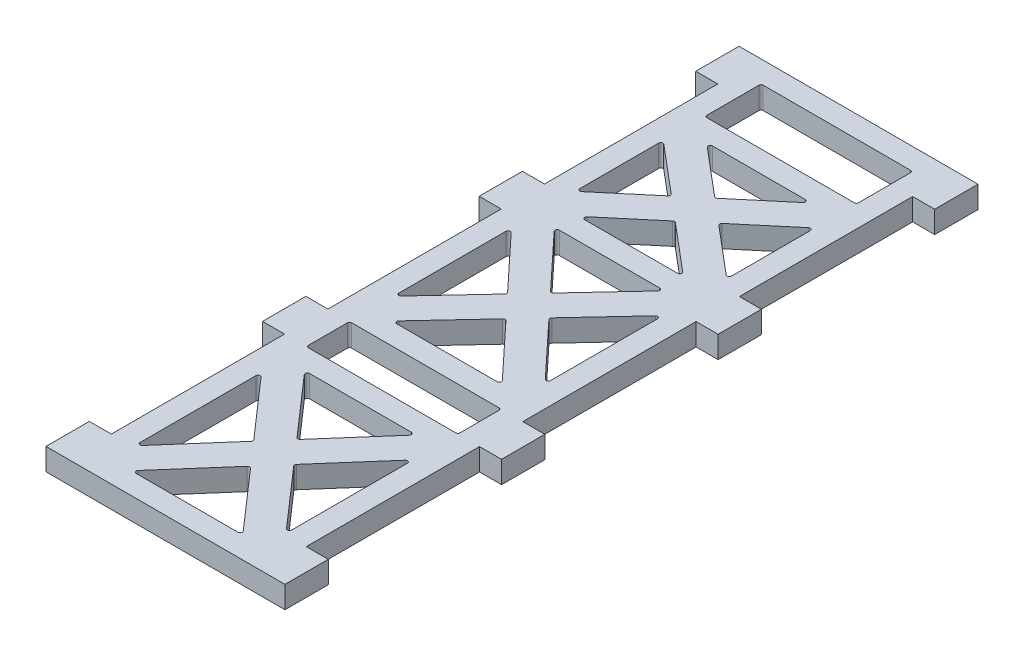
from build123d import *

# Parameters (mm, degrees)
SKETCH1_W           = 45
SKETCH1_H           = 160
BOSS_EXTRUDE1_DEPTH = 5.08
SKETCH2_W           = 5.08
SKETCH2_H           = 10
BOSS_EXTRUDE2_DEPTH = 5.08
SKETCH3_W           = 35
SKETCH3_H           = 13
SKETCH3_H_2         = 29.5
SKETCH3_H_3         = 37.5
SKETCH3_H_4         = 10
SKETCH3_H_5         = 40
CUT_EXTRUDE1_DEPTH  = 6.08
BOSS_EXTRUDE3_DEPTH = 5.08
FILLET1_R           = 0.5


with BuildPart() as part:
    # Sketch1 → Boss-Extrude1 (new body)
    with BuildSketch(Plane(origin=(0, 0, 0), x_dir=(1, 0, 0), z_dir=(0, 1, 0))):
        Rectangle(SKETCH1_W, SKETCH1_H)
    extrude(amount=BOSS_EXTRUDE1_DEPTH)

    # Sketch2 → Boss-Extrude2 (add)
    with BuildSketch(Plane(origin=(0, 5.08, 0), x_dir=(1, 0, 0), z_dir=(0, 1, 0))):
        with Locations((25.04, 25)):
            Rectangle(SKETCH2_W, SKETCH2_H)
        with Locations((25.04, 75)):
            Rectangle(SKETCH2_W, SKETCH2_H)
        with Locations((25.04, -25)):
            Rectangle(SKETCH2_W, SKETCH2_H)
        with Locations((25.04, -75)):
            Rectangle(SKETCH2_W, SKETCH2_H)
    boss_extrude2 = extrude(amount=-BOSS_EXTRUDE2_DEPTH)

    # Mirror1: Boss-Extrude2 across plane
    add(boss_extrude2.mirror(Plane(origin=(0, 0, 0), x_dir=(0, 0, 1), z_dir=(1, 0, 0))))

    # Sketch3 → Cut-Extrude1 (cut, through all)
    with BuildSketch(Plane(origin=(0, 5.08, 0), x_dir=(1, 0, 0), z_dir=(0, 1, 0))):
        with Locations((0, 68.5)):
            Rectangle(SKETCH3_W, SKETCH3_H)
        with Locations((0, 42.25)):
            Rectangle(SKETCH3_W, SKETCH3_H_2)
        with Locations((0, 3.75)):
            Rectangle(SKETCH3_W, SKETCH3_H_3)
        with Locations((0, -25)):
            Rectangle(SKETCH3_W, SKETCH3_H_4)
        with Locations((0, -55)):
            Rectangle(SKETCH3_W, SKETCH3_H_5)
    extrude(amount=-CUT_EXTRUDE1_DEPTH, mode=Mode.SUBTRACT)

    # Sketch4 → Boss-Extrude3 (add)
    with BuildSketch(Plane(origin=(0, 5.08, 0), x_dir=(1, 0, 0), z_dir=(0, 1, 0))):
        Polygon((-17.5, -40.315072906), (-4.650688793, -55), (-17.5, -69.684927094), (-17.5, -75), (-12.849311207, -75), (0, -60.315072906), (12.849311207, -75), (17.5, -75), (17.5, -69.684927094), (4.650688793, -55), (17.5, -40.315072906), (17.5, -35), (12.849311207, -35), (0, -49.684927094), (-12.849311207, -35), (-17.5, -35), align=None)
        Polygon((-12.712400277, 22.5), (0, 8.879571132), (12.712400277, 22.5), (17.5, 22.5), (17.5, 17.370428868), (4.787599723, 3.75), (17.5, -9.870428868), (17.5, -15), (12.712400277, -15), (0, -1.379571132), (-12.712400277, -15), (-17.5, -15), (-17.5, -9.870428868), (-4.787599723, 3.75), (-17.5, 17.370428868), (-17.5, 22.5), align=None)
        Polygon((-17.5, 52.422609914), (-5.430801797, 42.25), (-17.5, 32.077390086), (-17.5, 27.5), (-12.069198203, 27.5), (0, 37.672609914), (12.069198203, 27.5), (17.5, 27.5), (17.5, 32.077390086), (5.430801797, 42.25), (17.5, 52.422609914), (17.5, 57), (12.069198203, 57), (0, 46.827390086), (-12.069198203, 57), (-17.5, 57), align=None)
    extrude(amount=-BOSS_EXTRUDE3_DEPTH)

    # Fillet1
    fillet1_edges = [part.edges().sort_by_distance(p)[0] for p in [
        (-17.5, 2.54, -62),
        (-17.5, 2.54, -75),
        (17.5, 2.54, -75),
        (17.5, 2.54, -62),
        (-17.5, 2.54, 30),
        (-17.5, 2.54, 20),
        (17.5, 2.54, 20),
        (17.5, 2.54, 30),
        (-12.849311207, 2.54, 75),
        (-17.5, 2.54, 69.684927094),
        (-4.650688793, 2.54, 55),
        (-17.5, 2.54, 40.315072906),
        (-12.849311207, 2.54, 35),
        (0, 2.54, 49.684927094),
        (12.849311207, 2.54, 35),
        (17.5, 2.54, 40.315072906),
        (4.650688793, 2.54, 55),
        (17.5, 2.54, 69.684927094),
        (12.849311207, 2.54, 75),
        (0, 2.54, 60.315072906),
        (-17.5, 2.54, 9.870428868),
        (-4.787599723, 2.54, -3.75),
        (-17.5, 2.54, -17.370428868),
        (-12.712400277, 2.54, -22.5),
        (0, 2.54, -8.879571132),
        (12.712400277, 2.54, -22.5),
        (17.5, 2.54, -17.370428868),
        (4.787599723, 2.54, -3.75),
        (17.5, 2.54, 9.870428868),
        (12.712400277, 2.54, 15),
        (0, 2.54, 1.379571132),
        (-12.712400277, 2.54, 15),
        (-12.069198203, 2.54, -27.5),
        (-17.5, 2.54, -32.077390086),
        (-5.430801797, 2.54, -42.25),
        (-17.5, 2.54, -52.422609914),
        (-12.069198203, 2.54, -57),
        (0, 2.54, -46.827390086),
        (12.069198203, 2.54, -57),
        (17.5, 2.54, -52.422609914),
        (5.430801797, 2.54, -42.25),
        (17.5, 2.54, -32.077390086),
        (12.069198203, 2.54, -27.5),
        (0, 2.54, -37.672609914),
    ]]
    fillet(fillet1_edges, radius=FILLET1_R)


solid = part.part
